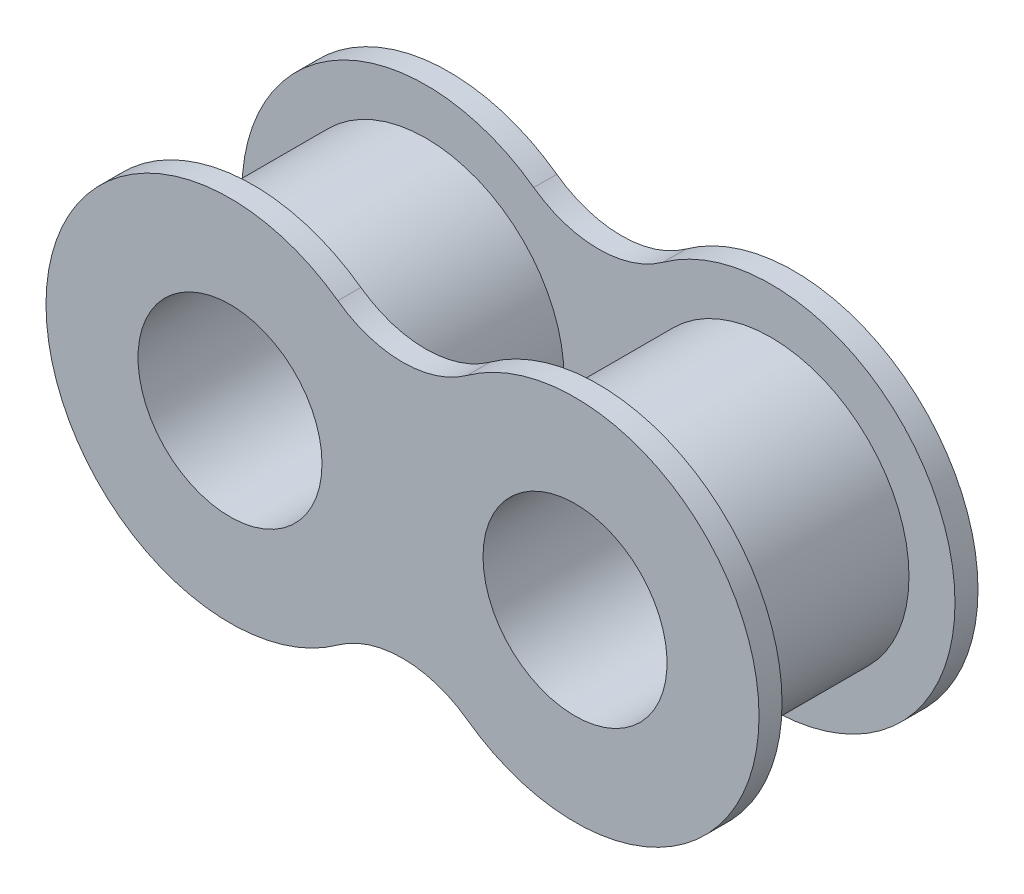
from build123d import *

# Parameters (mm, degrees)
SKETCH1_R           = 2.54
BOSS_EXTRUDE1_DEPTH = 0.635
SKETCH2_R           = 3.81
SKETCH2_R_2         = 2.54
BOSS_EXTRUDE2_DEPTH = 4.7752


with BuildPart() as part:
    # Sketch1 → Boss-Extrude1 (new body)
    with BuildSketch(Plane.XY):
        with BuildLine():
            ThreePointArc((-1.7859375, 4.116609732), (-9.8425, 0), (-1.7859375, -4.116609732))
            ThreePointArc((-1.7859375, -4.116609732), (0, -3.538575571), (1.7859375, -4.116609732))
            ThreePointArc((1.7859375, -4.116609732), (9.8425, 0), (1.7859375, 4.116609732))
            ThreePointArc((1.7859375, 4.116609732), (0, 3.538575571), (-1.7859375, 4.116609732))
        make_face()
        with Locations((-4.7625, 0)):
            Circle(SKETCH1_R, mode=Mode.SUBTRACT)
        with Locations((4.7625, 0)):
            Circle(SKETCH1_R, mode=Mode.SUBTRACT)
    boss_extrude1 = extrude(amount=BOSS_EXTRUDE1_DEPTH)

    # Sketch2 → Boss-Extrude2 (add)
    with BuildSketch(Plane.XY.offset(0.635)):
        with Locations((-4.7625, 0)):
            Circle(SKETCH2_R)
        with Locations((-4.7625, 0)):
            Circle(SKETCH2_R_2, mode=Mode.SUBTRACT)
    boss_extrude2 = extrude(amount=BOSS_EXTRUDE2_DEPTH)

    # Mirror1: Boss-Extrude2 across plane
    add(boss_extrude2.mirror(Plane(origin=(0, 0, 0), x_dir=(0, 0, 1), z_dir=(1, 0, 0))))

    # Mirror2: Boss-Extrude1 across plane
    add(boss_extrude1.mirror(Plane.XY.offset(3.0226)))


solid = part.part
